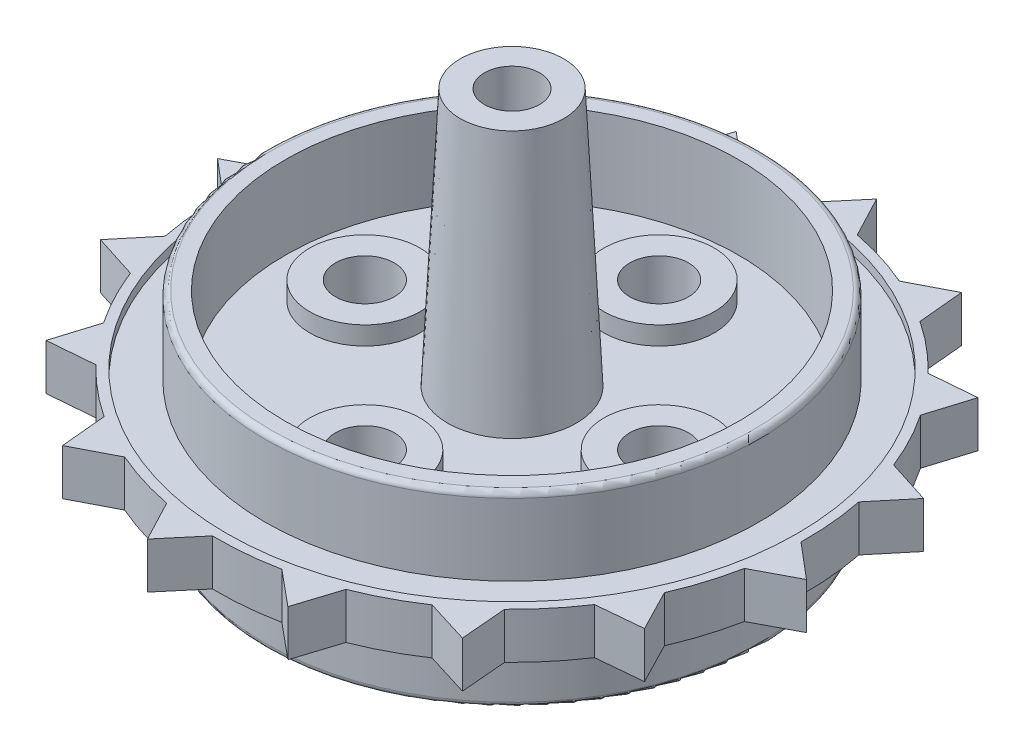
from build123d import *

# Parameters (mm, degrees)
SKETCH1_R           = 13.425
BOSS_EXTRUDE1_DEPTH = 4
SKETCH2_R           = 16
BOSS_EXTRUDE2_DEPTH = 2.5
SKETCH4_R           = 12.325
CUT_EXTRUDE1_DEPTH  = 4
SKETCH6_R           = 15.5
CUT_EXTRUDE3_DEPTH  = 0.5
SKETCH5_R           = 15.5
CUT_EXTRUDE4_DEPTH  = 0.5
SKETCH7_R           = 5.500000049
SKETCH7_R_2         = 3
BOSS_EXTRUDE4_DEPTH = 1
SKETCH8_R           = 3.2
BOSS_EXTRUDE5_DEPTH = 4.3
FILLET1_R           = 1
SKETCH10_R          = 13.425
BOSS_EXTRUDE6_DEPTH = 4.2
SKETCH11_R          = 12.325
CUT_EXTRUDE6_DEPTH  = 4.5
SKETCH12_R          = 3.5
BOSS_EXTRUDE7_DEPTH = 14
BOSS_EXTRUDE7_TAPER = 2.8
SKETCH13_R          = 1.5
CUT_EXTRUDE7_DEPTH  = 14
FILLET2_R           = 0.3
FILLET3_R           = 0.3
SKETCH14_R          = 1.6
CUT_EXTRUDE8_DEPTH  = 5
SKETCH15_R          = 3
SKETCH15_R_2        = 1.6
BOSS_EXTRUDE8_DEPTH = 1
BOSS_EXTRUDE9_DEPTH = 2.5


with BuildPart() as part:
    # Sketch1 → Boss-Extrude1 (new body)
    with BuildSketch(Plane(origin=(0, 0, 0), x_dir=(1, 0, 0), z_dir=(0, 1, 0))):
        Circle(SKETCH1_R)
    extrude(amount=BOSS_EXTRUDE1_DEPTH)

    # Sketch2 → Boss-Extrude2 (add)
    with BuildSketch(Plane(origin=(0, 4, 0), x_dir=(1, 0, 0), z_dir=(0, 1, 0))):
        Circle(SKETCH2_R)
    extrude(amount=BOSS_EXTRUDE2_DEPTH)

    # Sketch4 → Cut-Extrude1 (cut)
    with BuildSketch(Plane.XZ):
        Circle(SKETCH4_R)
    extrude(amount=-CUT_EXTRUDE1_DEPTH, mode=Mode.SUBTRACT)

    # Sketch6 → Cut-Extrude3 (cut)
    with BuildSketch(Plane(origin=(0, 6.5, 0), x_dir=(1, 0, 0), z_dir=(0, 1, 0))):
        Circle(SKETCH6_R)
    extrude(amount=-CUT_EXTRUDE3_DEPTH, mode=Mode.SUBTRACT)

    # Sketch5 → Cut-Extrude4 (cut)
    with BuildSketch(Plane.XZ.offset(-4)):
        Circle(SKETCH5_R)
    extrude(amount=-CUT_EXTRUDE4_DEPTH, mode=Mode.SUBTRACT)

    # Sketch7 → Boss-Extrude4 (add)
    with BuildSketch(Plane.XZ.offset(-4.5)):
        Circle(SKETCH7_R)
        with Locations((0, 8)):
            Circle(SKETCH7_R_2)
        with Locations((8, 0)):
            Circle(SKETCH7_R_2)
        with Locations((0, -8)):
            Circle(SKETCH7_R_2)
        with Locations((-8, 0)):
            Circle(SKETCH7_R_2)
    extrude(amount=BOSS_EXTRUDE4_DEPTH)

    # Sketch8 → Boss-Extrude5 (add)
    with BuildSketch(Plane.XZ.offset(-3.5)):
        Circle(SKETCH8_R)
    extrude(amount=BOSS_EXTRUDE5_DEPTH)

    # Fillet1
    fillet1_edges = [part.edges().sort_by_distance(p)[0] for p in [
        (-3.2, -0.8, 0),
    ]]
    fillet(fillet1_edges, radius=FILLET1_R)

    # Sketch10 → Boss-Extrude6 (add)
    with BuildSketch(Plane(origin=(0, 6, 0), x_dir=(1, 0, 0), z_dir=(0, 1, 0))):
        Circle(SKETCH10_R)
    extrude(amount=BOSS_EXTRUDE6_DEPTH)

    # Sketch11 → Cut-Extrude6 (cut)
    with BuildSketch(Plane(origin=(0, 10.2, 0), x_dir=(1, 0, 0), z_dir=(0, 1, 0))):
        Circle(SKETCH11_R)
    extrude(amount=-CUT_EXTRUDE6_DEPTH, mode=Mode.SUBTRACT)

    # Sketch12 → Boss-Extrude7 (add)
    with BuildSketch(Plane(origin=(0, 5.7, 0), x_dir=(1, 0, 0), z_dir=(0, 1, 0))):
        Circle(SKETCH12_R)
    extrude(amount=BOSS_EXTRUDE7_DEPTH, taper=BOSS_EXTRUDE7_TAPER)

    # Sketch13 → Cut-Extrude7 (cut)
    with BuildSketch(Plane(origin=(0, 19.7, 0), x_dir=(1, 0, 0), z_dir=(0, 1, 0))):
        Circle(SKETCH13_R)
    extrude(amount=-CUT_EXTRUDE7_DEPTH, mode=Mode.SUBTRACT)

    # Fillet2
    fillet2_edges = [part.edges().sort_by_distance(p)[0] for p in [
        (-13.425, 0, 0),
    ]]
    fillet(fillet2_edges, radius=FILLET2_R)

    # Fillet3
    fillet3_edges = [part.edges().sort_by_distance(p)[0] for p in [
        (-13.425, 10.2, 0),
    ]]
    fillet(fillet3_edges, radius=FILLET3_R)

    # Sketch14 → Cut-Extrude8 (cut)
    with BuildSketch(Plane.XZ.offset(-3.5)):
        with Locations((0, -8)):
            Circle(SKETCH14_R)
        with Locations((-8, 0)):
            Circle(SKETCH14_R)
        with Locations((0, 8)):
            Circle(SKETCH14_R)
        with Locations((8, 0)):
            Circle(SKETCH14_R)
    extrude(amount=-CUT_EXTRUDE8_DEPTH, mode=Mode.SUBTRACT)

    # Sketch15 → Boss-Extrude8 (add)
    with BuildSketch(Plane(origin=(0, 5.7, 0), x_dir=(1, 0, 0), z_dir=(0, 1, 0))):
        with Locations((8, 0)):
            Circle(SKETCH15_R)
        with Locations((8, 0)):
            Circle(SKETCH15_R_2, mode=Mode.SUBTRACT)
        with Locations((0, -8)):
            Circle(SKETCH15_R)
        with Locations((0, -8)):
            Circle(SKETCH15_R_2, mode=Mode.SUBTRACT)
        with Locations((-8, 0)):
            Circle(SKETCH15_R)
        with Locations((-8, 0)):
            Circle(SKETCH15_R_2, mode=Mode.SUBTRACT)
        with Locations((0, 8)):
            Circle(SKETCH15_R)
        with Locations((0, 8)):
            Circle(SKETCH15_R_2, mode=Mode.SUBTRACT)
    extrude(amount=BOSS_EXTRUDE8_DEPTH)

    # Sketch16 → Boss-Extrude9 (add)
    with BuildSketch(Plane.XZ.offset(-4)):
        Polygon((-11.109366612, -11.514424583), (-11.320042521, -14.014424583), (-8.93195872, -13.274792406), align=None)
        Polygon((-14.670095953, -6.386570655), (-15.821443695, -8.615647306), (-13.332096968, -8.846196382), align=None)
        Polygon((-15.99743617, -0.286419239), (-17.914173487, -1.905215827), (-15.702544309, -3.070847149), align=None)
        Polygon((-14.889311748, 5.85733691), (-17.279632759, 5.09526749), (-15.682421623, 3.172010724), align=None)
        Polygon((-11.514424583, 11.109366612), (-14.014424583, 11.320042521), (-13.274792406, 8.93195872), align=None)
        Polygon((-6.386570655, 14.670095953), (-8.615647306, 15.821443695), (-8.846196382, 13.332096968), align=None)
        Polygon((-0.286419239, 15.99743617), (-1.905215827, 17.914173487), (-3.070847149, 15.702544309), align=None)
        Polygon((5.85733691, 14.889311748), (5.09526749, 17.279632759), (3.172010724, 15.682421623), align=None)
        Polygon((11.109366612, 11.514424583), (11.320042521, 14.014424583), (8.93195872, 13.274792406), align=None)
        Polygon((14.670095953, 6.386570655), (15.821443695, 8.615647306), (13.332096968, 8.846196382), align=None)
        Polygon((15.99743617, 0.286419239), (17.914173487, 1.905215827), (15.702544309, 3.070847149), align=None)
        Polygon((14.889311748, -5.85733691), (17.279632759, -5.09526749), (15.682421623, -3.172010724), align=None)
        Polygon((11.514424583, -11.109366612), (14.014424583, -11.320042521), (13.274792406, -8.93195872), align=None)
        Polygon((6.386570655, -14.670095953), (8.615647306, -15.821443695), (8.846196382, -13.332096968), align=None)
        Polygon((0.286419239, -15.99743617), (1.905215827, -17.914173487), (3.070847149, -15.702544309), align=None)
        Polygon((-5.85733691, -14.889311748), (-5.09526749, -17.279632759), (-3.172010724, -15.682421623), align=None)
    extrude(amount=-BOSS_EXTRUDE9_DEPTH)


solid = part.part
